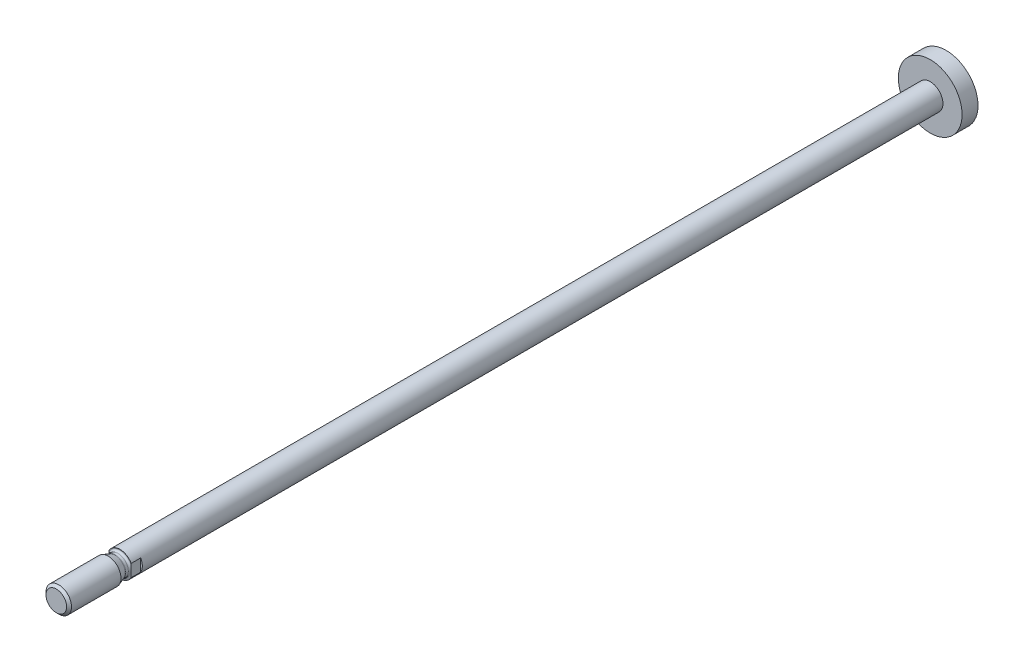
from build123d import *

# Parameters (mm, degrees)
SCHNITT_LINEAR_AUSTRAGEN1_DEPTH = 4


with BuildPart() as part:
    # Skizze1 → Rotation1 (revolve)
    with BuildSketch(Plane(origin=(0, 0, 0), x_dir=(0, 0, -1), z_dir=(1, 0, 0))):
        Polygon((-4, 0), (-4, 4), (250.3, 4), (250.3, 10), (255.3, 10), (255.3, 0), align=None)
    revolve(axis=Axis((0, 0, -255.3), (0, 0, 1)))

    # Skizze2 → Rotation2 (revolve)
    with BuildSketch(Plane(origin=(0, 0, 0), x_dir=(0, 0, -1), z_dir=(1, 0, 0))):
        with BuildLine():
            Line((-24, 0), (-24, 3.233))
            Line((-24, 3.233), (-23.233, 4))
            Line((-23.233, 4), (-7.697981936, 4))
            Line((-7.697981936, 4), (-5.599415898, 3.236184428))
            ThreePointArc((-5.599415898, 3.236184428), (-5.498392718, 3.209115348), (-5.394203812, 3.2))
            Line((-5.394203812, 3.2), (-4.6, 3.2))
            ThreePointArc((-4.6, 3.2), (-4.175735931, 3.375735931), (-4, 3.8))
            Line((-4, 3.8), (-4, 4))
            Line((-4, 4), (-3, 4))
            Line((-3, 4), (-3, 0))
            Line((-3, 0), (-24, 0))
        make_face()
    revolve(axis=Axis((0, 0, 3), (0, 0, 1)))

    # Skizze3 → Schnitt-Linear austragen1 (cut)
    with BuildSketch(Plane.XY.offset(1)):
        Polygon((-7, 14), (-7, -7), (-3.5, -7), (-3.5, 7), (3.5, 7), (3.5, -7), (7, -7), (7, 14), align=None)
    extrude(amount=SCHNITT_LINEAR_AUSTRAGEN1_DEPTH, mode=Mode.SUBTRACT)


solid = part.part
